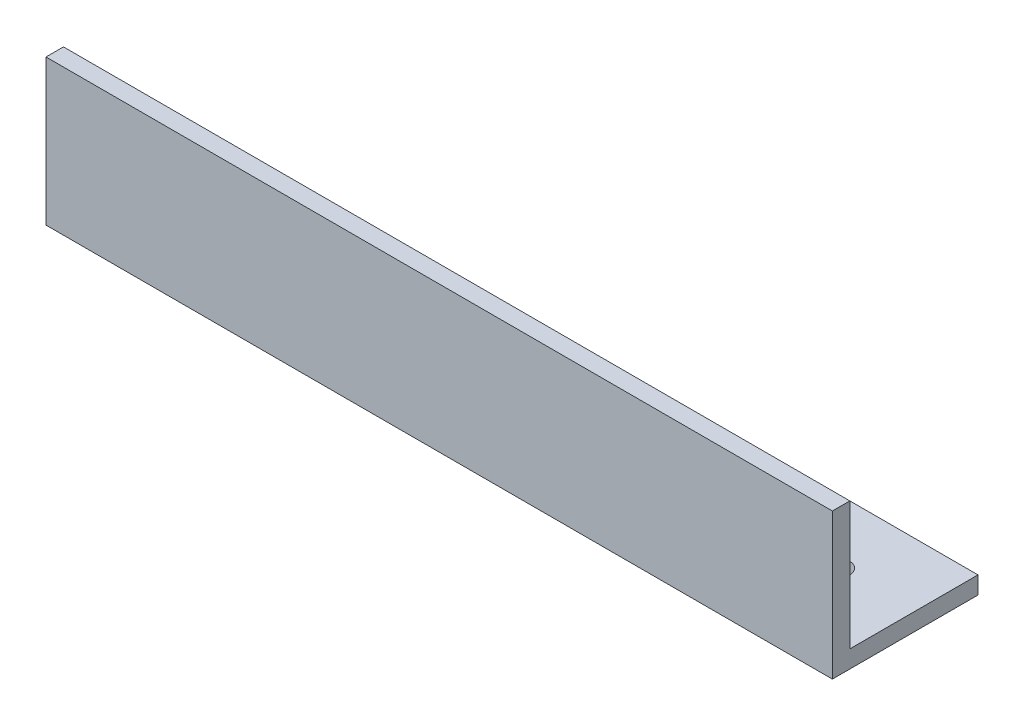
from build123d import *

# Parameters (mm, degrees)
EXTRUDE_2_DEPTH     = 270
SKETCH_2_R          = 4
CUT_EXTRUDE_1_DEPTH = 51


with BuildPart() as part:
    # Эскиз1 → Вытянуть-Тонкостенный2 (new body)
    with BuildSketch(Plane(origin=(0, 0, 0), x_dir=(0, 0, -1), z_dir=(1, 0, 0))):
        Polygon((0, 50), (0, 0), (50, 0), (50, 6), (6, 6), (6, 50), align=None)
    extrude(amount=EXTRUDE_2_DEPTH)

    # Эскиз2 → Вырез-Вытянуть1 (cut, through all)
    with BuildSketch(Plane.XZ):
        with Locations((26, -28)):
            Circle(SKETCH_2_R)
        with Locations((244, -28)):
            Circle(SKETCH_2_R)
    extrude(amount=-CUT_EXTRUDE_1_DEPTH, mode=Mode.SUBTRACT)


solid = part.part
